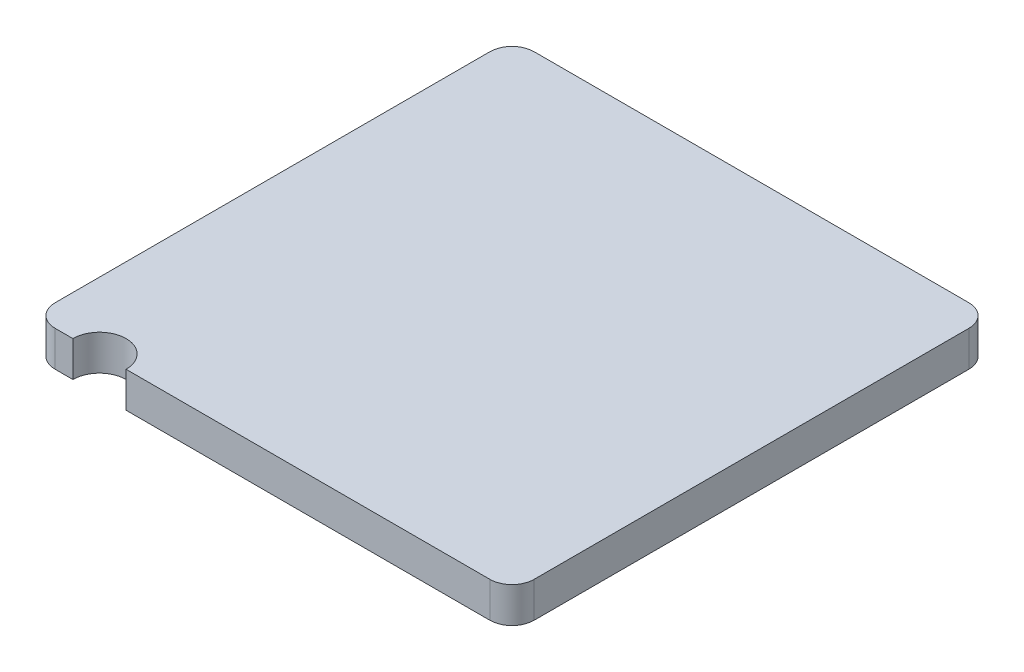
from build123d import *

# Parameters (mm, degrees)
SKETCH1_W           = 2.7
SKETCH1_H           = 2.7
BOSS_EXTRUDE1_DEPTH = 0.2
FILLET1_R           = 0.125
CUT_EXTRUDE2_DEPTH  = 1.2


with BuildPart() as part:
    # Sketch1 → Boss-Extrude1 (new body)
    with BuildSketch(Plane(origin=(0, 0, 0), x_dir=(1, 0, 0), z_dir=(0, 1, 0))):
        Rectangle(SKETCH1_W, SKETCH1_H)
    extrude(amount=BOSS_EXTRUDE1_DEPTH)

    # Fillet1
    fillet1_edges = [part.edges().sort_by_distance(p)[0] for p in [
        (1.35, 0.1, 1.35),
        (-1.35, 0.1, 1.35),
        (-1.35, 0.1, -1.35),
        (1.35, 0.1, -1.35),
    ]]
    fillet(fillet1_edges, radius=FILLET1_R)

    # Sketch3 → Cut-Extrude2 (cut, through all)
    with BuildSketch(Plane.XZ):
        with BuildLine():
            Line((-1.125, 1.35), (-0.825, 1.35))
            ThreePointArc((-0.825, 1.35), (-0.975, 1.2), (-1.125, 1.35))
        make_face()
    extrude(amount=-CUT_EXTRUDE2_DEPTH, mode=Mode.SUBTRACT)


solid = part.part
